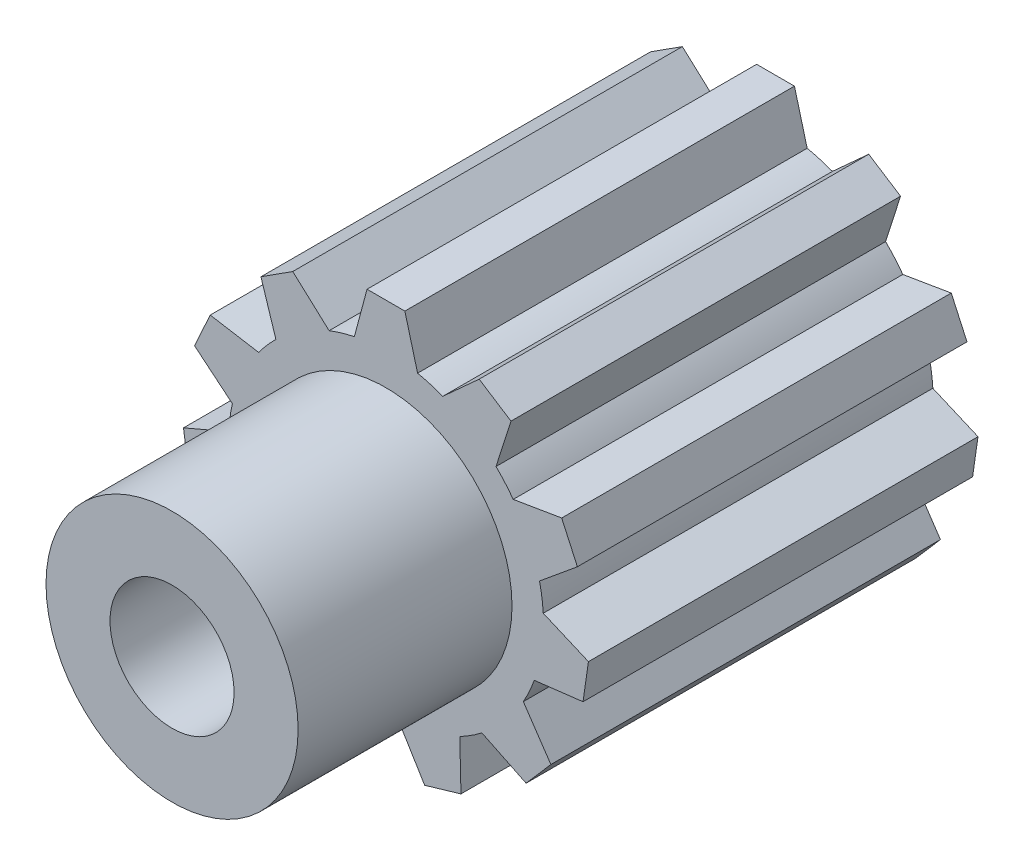
from build123d import *

# Parameters (mm, degrees)
SKETCH1_R           = 6.35
BOSS_EXTRUDE1_DEPTH = 15.7
BOSS_EXTRUDE2_DEPTH = 15.7
CIRPATTERN1_COUNT   = 11
SKETCH3_R           = 5.08
BOSS_EXTRUDE3_DEPTH = 8.62
SKETCH4_R           = 2.5
CUT_EXTRUDE1_DEPTH  = 25.32


with BuildPart() as part:
    # Sketch1 → Boss-Extrude1 (new body)
    with BuildSketch(Plane.XY):
        Circle(SKETCH1_R)
    extrude(amount=BOSS_EXTRUDE1_DEPTH)

    # Sketch2 → Boss-Extrude2 (add)
    with BuildSketch(Plane.XY.offset(15.7)):
        Polygon((0, 8.13319935), (-0.762, 8.13319935), (-1.388433627, 5.795317226), (1.388433627, 5.795317226), (0.762, 8.13319935), align=None)
    boss_extrude2 = extrude(amount=-BOSS_EXTRUDE2_DEPTH)

    # CirPattern1: Boss-Extrude2 ×11 about axis
    cirpattern1_axis = Axis((0, 0, 0), (0, 0, 1))
    for i in range(1, CIRPATTERN1_COUNT):
        add(boss_extrude2.rotate(cirpattern1_axis, i * 360 / CIRPATTERN1_COUNT))

    # Sketch3 → Boss-Extrude3 (add)
    with BuildSketch(Plane.XY.offset(15.7)):
        Circle(SKETCH3_R)
    extrude(amount=BOSS_EXTRUDE3_DEPTH)

    # Sketch4 → Cut-Extrude1 (cut, through all)
    with BuildSketch(Plane.XY.offset(24.32)):
        Circle(SKETCH4_R)
    extrude(amount=-CUT_EXTRUDE1_DEPTH, mode=Mode.SUBTRACT)


solid = part.part
